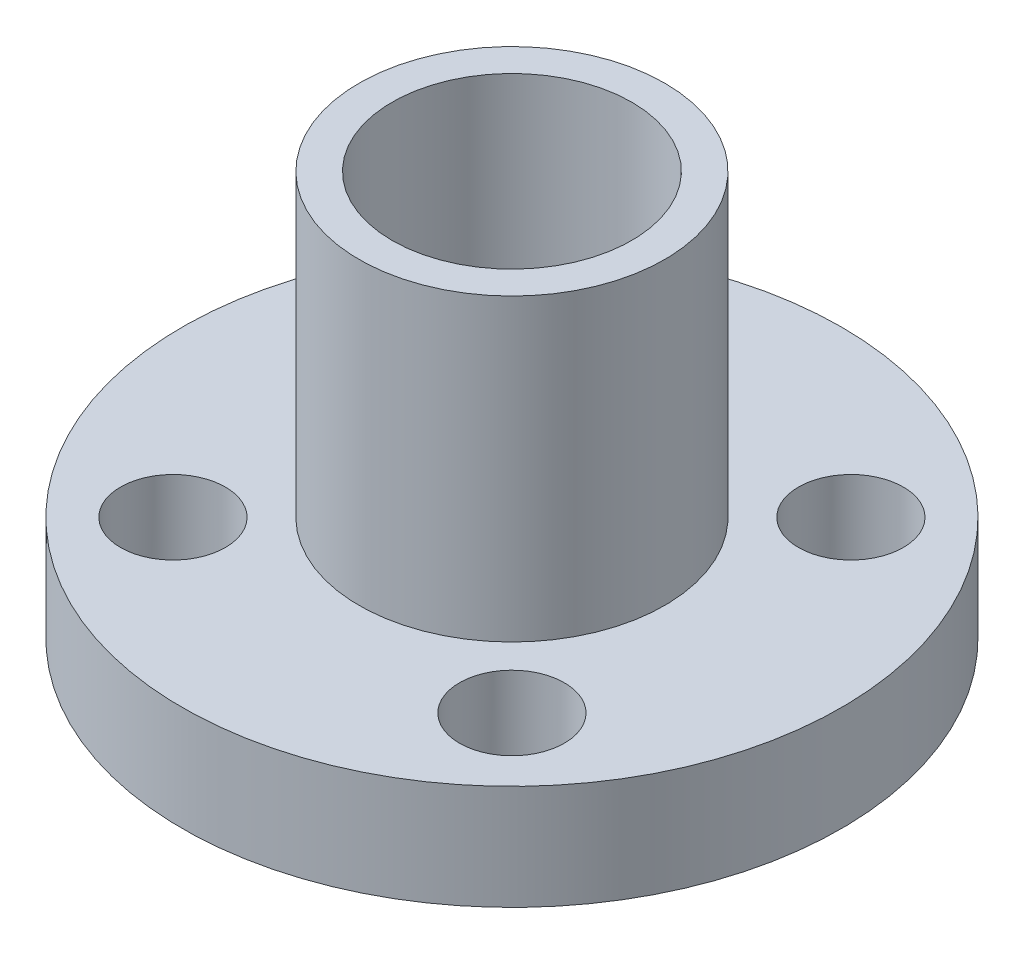
from build123d import *

# Parameters (mm, degrees)
SKETCH2_W                           = 1.75
SKETCH2_H                           = 5
F_3_5_3_5_DIAMETER_HOLE1_AT_2_COUNT = 2
F_3_5_3_5_DIAMETER_HOLE1_AT_2_PITCH = 11.313708499
F_3_5_3_5_DIAMETER_HOLE1_AT_3_COUNT = 2
F_3_5_3_5_DIAMETER_HOLE1_AT_3_PITCH = 16
F_3_5_3_5_DIAMETER_HOLE1_AT_4_COUNT = 2
F_3_5_3_5_DIAMETER_HOLE1_AT_4_PITCH = 11.313708499
F_3_5_3_5_DIAMETER_HOLE1_AT_5_COUNT = 2
F_3_5_3_5_DIAMETER_HOLE1_AT_5_PITCH = 8
F_8_0_8_DIAMETER_HOLE1_D            = 8


with BuildPart() as part:
    # Sketch1 → Revolve1 (revolve)
    with BuildSketch(Plane.XY):
        Polygon((0, 0), (0, 15), (5.1, 15), (5.1, 5), (11, 5), (11, 1.5), (5.1, 1.5), (5.1, 0), align=None)
    revolve(axis=Axis((0, 0, 0), (0, 1, 0)))

    # Sketch2 → Ø3.5 (3.5) Diameter Hole1 (revolve, cut)
    with BuildSketch(Plane(origin=(-5.656854249, 5, 5.656854249), x_dir=(0, 0, 1), z_dir=(1, 0, 0))):
        with Locations((0.875, 2.5)):
            Rectangle(SKETCH2_W, SKETCH2_H)
    f_3_5_3_5_diameter_hole1 = revolve(axis=Axis((-5.656854249, 11.35, 5.656854249), (0, -1, 0)), mode=Mode.SUBTRACT)

    # Ø3.5 (3.5) Diameter Hole1 at 2: Ø3.5 (3.5) Diameter Hole1 ×2
    with Locations(*[(i * F_3_5_3_5_DIAMETER_HOLE1_AT_2_PITCH, 0, 0) for i in range(1, F_3_5_3_5_DIAMETER_HOLE1_AT_2_COUNT)]):
        add(f_3_5_3_5_diameter_hole1, mode=Mode.SUBTRACT)

    # Ø3.5 (3.5) Diameter Hole1 at 3: Ø3.5 (3.5) Diameter Hole1 ×2
    with Locations(*[Vector(0.707106781, 0, -0.707106781) * (i * F_3_5_3_5_DIAMETER_HOLE1_AT_3_PITCH) for i in range(1, F_3_5_3_5_DIAMETER_HOLE1_AT_3_COUNT)]):
        add(f_3_5_3_5_diameter_hole1, mode=Mode.SUBTRACT)

    # Ø3.5 (3.5) Diameter Hole1 at 4: Ø3.5 (3.5) Diameter Hole1 ×2
    with Locations(*[(0, 0, -i * F_3_5_3_5_DIAMETER_HOLE1_AT_4_PITCH) for i in range(1, F_3_5_3_5_DIAMETER_HOLE1_AT_4_COUNT)]):
        add(f_3_5_3_5_diameter_hole1, mode=Mode.SUBTRACT)

    # Ø3.5 (3.5) Diameter Hole1 at 5: Ø3.5 (3.5) Diameter Hole1 ×2
    with Locations(*[Vector(0.707106781, 0, -0.707106781) * (i * F_3_5_3_5_DIAMETER_HOLE1_AT_5_PITCH) for i in range(1, F_3_5_3_5_DIAMETER_HOLE1_AT_5_COUNT)]):
        add(f_3_5_3_5_diameter_hole1, mode=Mode.SUBTRACT)

    # Ø8.0 (8) Diameter Hole1 (through all)
    with Locations(Plane(origin=(0, 15, 0), x_dir=(1, 0, 0), z_dir=(0, 1, 0))):
        with Locations((0, 0)):
            Hole(F_8_0_8_DIAMETER_HOLE1_D / 2)


solid = part.part
